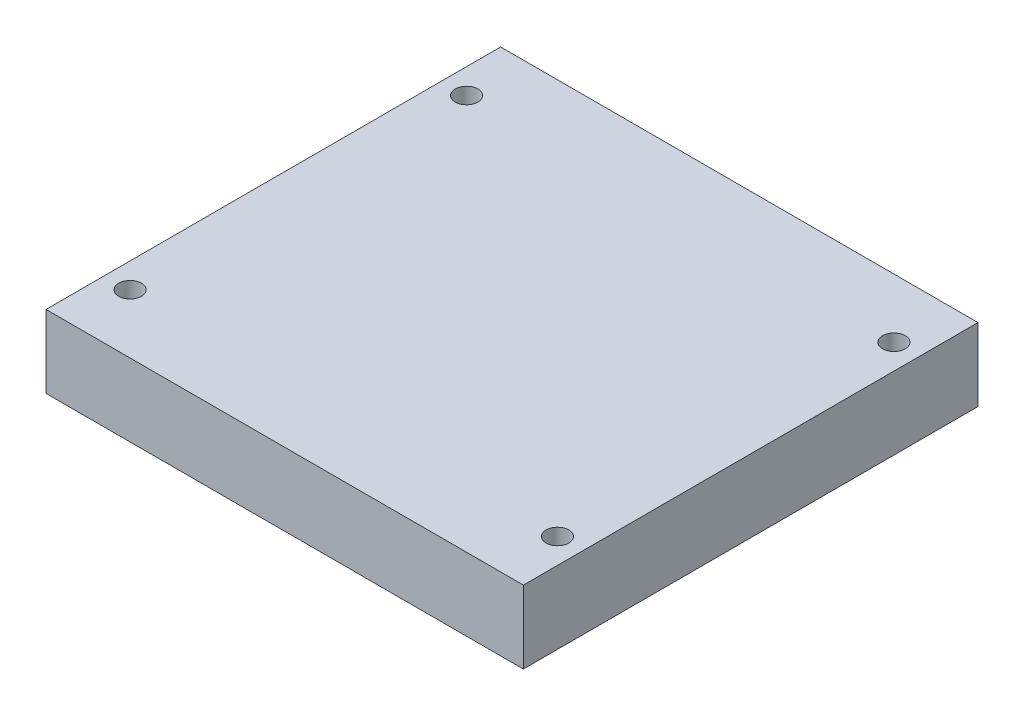
from build123d import *

# Parameters (mm, degrees)
SKETCH1_W           = 105
SKETCH1_H           = 100
SKETCH1_R           = 2.5
BOSS_EXTRUDE2_DEPTH = 16
SKETCH2_R           = 45
CUT_EXTRUDE1_DEPTH  = 12
CHAMFER1_SIZE       = 5


with BuildPart() as part:
    # Sketch1 → Boss-Extrude2 (new body)
    with BuildSketch(Plane(origin=(0, 0, 0), x_dir=(1, 0, 0), z_dir=(0, 1, 0))):
        Rectangle(SKETCH1_W, SKETCH1_H)
        with Locations((47, -37)):
            Circle(SKETCH1_R, mode=Mode.SUBTRACT)
        with Locations((47, 37)):
            Circle(SKETCH1_R, mode=Mode.SUBTRACT)
        with Locations((-47, 37)):
            Circle(SKETCH1_R, mode=Mode.SUBTRACT)
        with Locations((-47, -37)):
            Circle(SKETCH1_R, mode=Mode.SUBTRACT)
    extrude(amount=BOSS_EXTRUDE2_DEPTH)

    # Sketch2 → Cut-Extrude1 (cut)
    with BuildSketch(Plane(origin=(0, 0, 0), x_dir=(1, 0, 0), z_dir=(0, 1, 0))):
        Circle(SKETCH2_R)
    extrude(amount=CUT_EXTRUDE1_DEPTH, mode=Mode.SUBTRACT)

    # Chamfer1
    chamfer1_edges = [part.edges().sort_by_distance(p)[0] for p in [
        (-45, 12, 0),
    ]]
    chamfer(chamfer1_edges, length=CHAMFER1_SIZE)


solid = part.part
